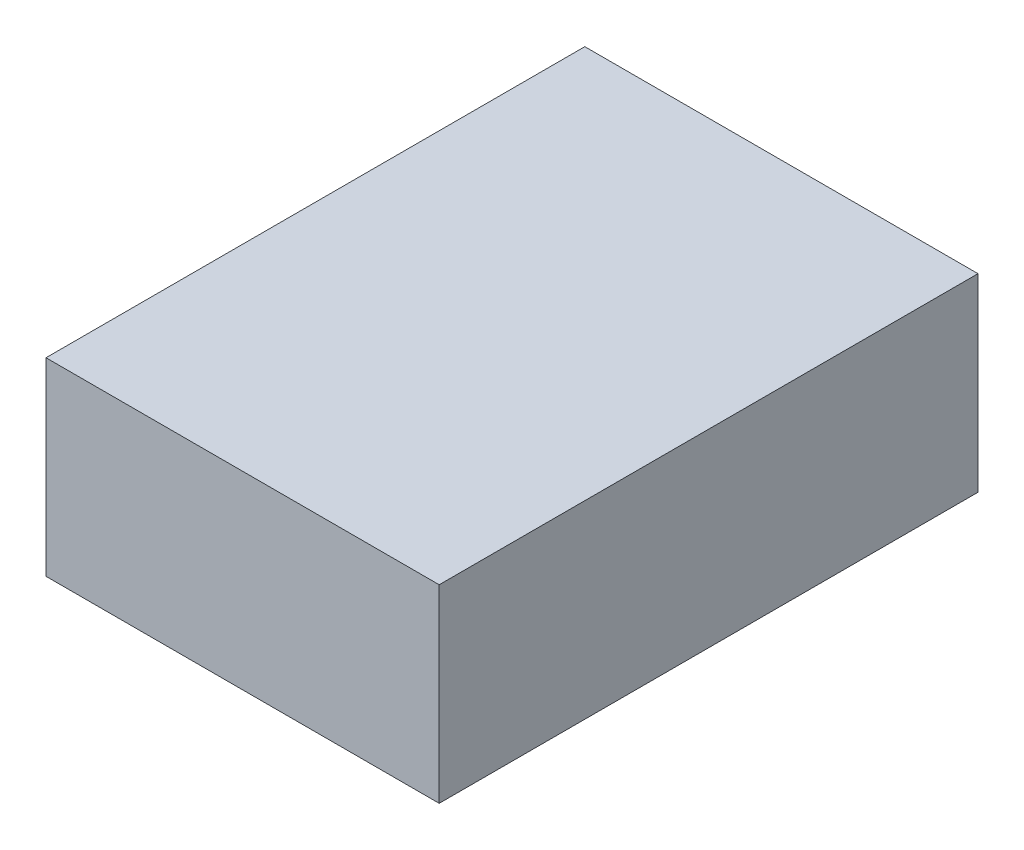
from build123d import *

# Parameters (mm, degrees)
SKETCH1_W           = 27
SKETCH1_H           = 37
BOSS_EXTRUDE1_DEPTH = 13


with BuildPart() as part:
    # Sketch1 → Boss-Extrude1 (new body)
    with BuildSketch(Plane(origin=(0, 0, 0), x_dir=(1, 0, 0), z_dir=(0, 1, 0))):
        Rectangle(SKETCH1_W, SKETCH1_H)
    extrude(amount=BOSS_EXTRUDE1_DEPTH)


solid = part.part
